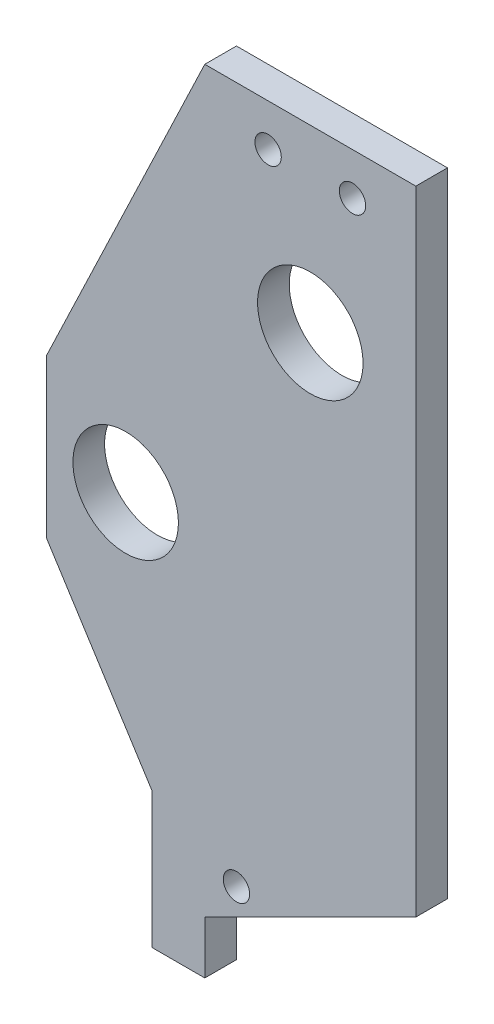
from build123d import *

# Parameters (mm, degrees)
SKETCH1_W           = 20
SKETCH1_H           = 70
BOSS_EXTRUDE1_DEPTH = 3
SKETCH2_W           = 15
SKETCH2_H           = 15
BOSS_EXTRUDE2_DEPTH = 3
BOSS_EXTRUDE3_DEPTH = 3
BOSS_EXTRUDE4_DEPTH = 3
SKETCH7_R           = 5
SKETCH7_R_2         = 1.25
CUT_EXTRUDE1_DEPTH  = 4


with BuildPart() as part:
    # Sketch1 → Boss-Extrude1 (new body)
    with BuildSketch(Plane.XY):
        with Locations((-6.20477445, -5.177042891)):
            Rectangle(SKETCH1_W, SKETCH1_H)
    extrude(amount=BOSS_EXTRUDE1_DEPTH)

    # Sketch2 → Boss-Extrude2 (add)
    with BuildSketch(Plane.XY.offset(3)):
        with Locations((-23.70477445, -9.077042891)):
            Rectangle(SKETCH2_W, SKETCH2_H)
    extrude(amount=-BOSS_EXTRUDE2_DEPTH)

    # Sketch3 → Boss-Extrude3 (add)
    with BuildSketch(Plane.XY.offset(3)):
        Polygon((-31.20477445, -1.577042891), (-16.20477445, 29.822957109), (-16.20477445, -1.577042891), align=None)
        Polygon((-31.20477445, -16.577042891), (-16.20477445, -16.577042891), (-16.20477445, -40.177042891), align=None)
    extrude(amount=-BOSS_EXTRUDE3_DEPTH)

    # Sketch6 → Boss-Extrude4 (add)
    with BuildSketch(Plane.XY.offset(3)):
        Polygon((-16.20477445, -40.177042891), (-16.20477445, -45.177042891), (-21.20477445, -45.177042891), (-21.20477445, -32.310376225), align=None)
    extrude(amount=-BOSS_EXTRUDE4_DEPTH)

    # Sketch7 → Cut-Extrude1 (cut, through all)
    with BuildSketch(Plane.XY.offset(3)):
        with Locations((-23.70477445, -9.077042891)):
            Circle(SKETCH7_R)
        with Locations((-13.20477445, -36.177042891)):
            Circle(SKETCH7_R_2)
        with Locations((-6.20477445, 12.780450103)):
            Circle(SKETCH7_R)
        with Locations((-10.20477445, 25.822957109)):
            Circle(SKETCH7_R_2)
        with Locations((-2.20477445, 25.822957109)):
            Circle(SKETCH7_R_2)
        Polygon((3.79522555, -40.177042891), (3.79522555, -30.177042891), (-16.20477445, -40.177042891), align=None)
    extrude(amount=-CUT_EXTRUDE1_DEPTH, mode=Mode.SUBTRACT)


solid = part.part
